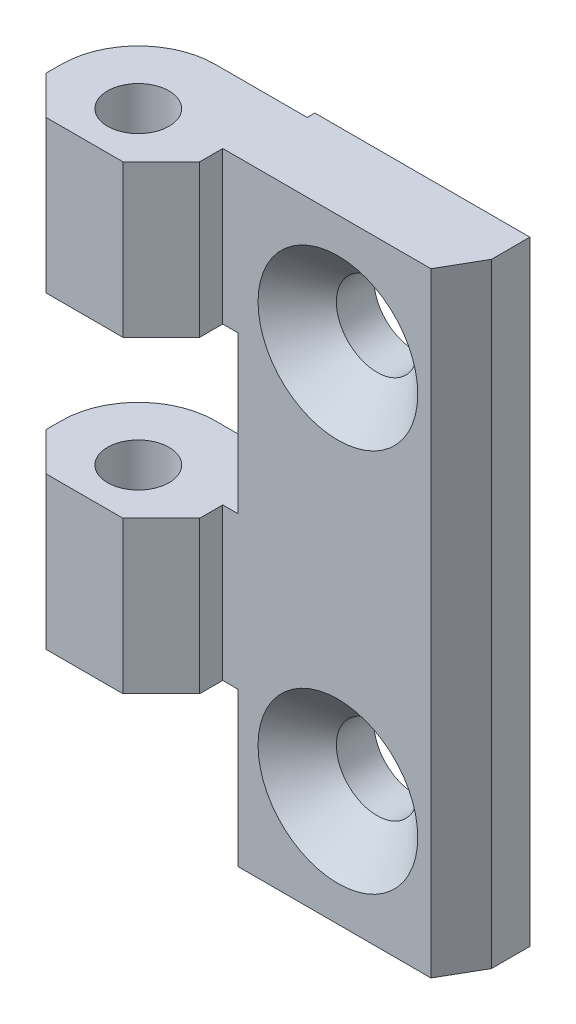
from build123d import *

# Parameters (mm, degrees)
BOSS_EXTRUDE1_DEPTH                            = 40
CUT_EXTRUDE1_DEPTH                             = 40
CSK_FOR_M5_FLAT_HEAD_MACHINE_SCREW1_AT_2_COUNT = 2
CSK_FOR_M5_FLAT_HEAD_MACHINE_SCREW1_AT_2_PITCH = 25
SKETCH7_R                                      = 2
CUT_EXTRUDE2_DEPTH                             = 40
SKETCH8_W                                      = 1
SKETCH8_H                                      = 10.2
CUT_EXTRUDE3_DEPTH                             = 10
SKETCH9_W                                      = 11.70124712
SKETCH9_H                                      = 10.2
CUT_EXTRUDE4_DEPTH                             = 10
CUT_EXTRUDE4_DEPTH_BACK                        = 10
SKETCH10_W                                     = 1
SKETCH10_H                                     = 10
CUT_EXTRUDE5_DEPTH                             = 10
SKETCH11_W                                     = 12.165826364
SKETCH11_H                                     = 10.874220792
CUT_EXTRUDE6_DEPTH                             = 10
CUT_EXTRUDE6_DEPTH_BACK                        = 10


with BuildPart() as part:
    # Sketch2 → Boss-Extrude1 (new body)
    with BuildSketch(Plane(origin=(0, 0, 0), x_dir=(1, 0, 0), z_dir=(0, 1, 0))):
        with BuildLine():
            Line((-2.5, 0), (2.5, 0))
            Line((2.5, 0), (5, 2.5))
            Line((5, 2.5), (5, 4))
            Line((5, 4), (20, 4))
            Line((20, 4), (20, 9))
            Line((20, 9), (6, 9))
            Line((6, 9), (6, 8.5))
            Line((6, 8.5), (0, 8.5))
            ThreePointArc((0, 8.5), (-3.535533906, 7.035533906), (-5, 3.5))
            Line((-5, 3.5), (-5, 2.5))
            Line((-5, 2.5), (-2.5, 0))
        make_face()
    extrude(amount=BOSS_EXTRUDE1_DEPTH)

    # Sketch3 → Cut-Extrude1 (cut)
    with BuildSketch(Plane(origin=(0, 40, 0), x_dir=(1, 0, 0), z_dir=(0, 1, 0))):
        Polygon((20, 6.5), (18.56, 4), (20, 4), align=None)
    extrude(amount=-CUT_EXTRUDE1_DEPTH, mode=Mode.SUBTRACT)

    # Sketch6 → CSK for M5 Flat Head Machine Screw1 (revolve, cut)
    with BuildSketch(Plane(origin=(12.5, 32.5, -4), x_dir=(0, -1, 0), z_dir=(1, 0, 0))):
        Polygon((0, 0), (0, 5), (2.65, 5), (2.65, 2.55), (5.2, 0), align=None)
    csk_for_m5_flat_head_machine_screw1 = revolve(axis=Axis((12.5, 32.5, 2.35), (0, 0, -1)), mode=Mode.SUBTRACT)

    # CSK for M5 Flat Head Machine Screw1 at 2: CSK for M5 Flat Head Machine Screw1 ×2
    with Locations(*[(0, -i * CSK_FOR_M5_FLAT_HEAD_MACHINE_SCREW1_AT_2_PITCH, 0) for i in range(1, CSK_FOR_M5_FLAT_HEAD_MACHINE_SCREW1_AT_2_COUNT)]):
        add(csk_for_m5_flat_head_machine_screw1, mode=Mode.SUBTRACT)

    # Sketch7 → Cut-Extrude2 (cut)
    with BuildSketch(Plane(origin=(0, 40, 0), x_dir=(1, 0, 0), z_dir=(0, 1, 0))):
        with Locations((0, 3.5)):
            Circle(SKETCH7_R)
    extrude(amount=-CUT_EXTRUDE2_DEPTH, mode=Mode.SUBTRACT)

    # Sketch8 → Cut-Extrude3 (cut)
    with BuildSketch(Plane.XY.offset(-4)):
        with Locations((5.5, 25)):
            Rectangle(SKETCH8_W, SKETCH8_H)
    extrude(amount=-CUT_EXTRUDE3_DEPTH, mode=Mode.SUBTRACT)

    # Sketch9 → Cut-Extrude4 (cut, two sides)
    with BuildSketch(Plane.XY.offset(-4)) as cut_extrude4_sk:
        with Locations((0.14937644, 25)):
            Rectangle(SKETCH9_W, SKETCH9_H)
    extrude(amount=CUT_EXTRUDE4_DEPTH, mode=Mode.SUBTRACT)
    extrude(cut_extrude4_sk.sketch, amount=-CUT_EXTRUDE4_DEPTH_BACK, mode=Mode.SUBTRACT)

    # Sketch10 → Cut-Extrude5 (cut)
    with BuildSketch(Plane.XY.offset(-4)):
        with Locations((5.5, 5)):
            Rectangle(SKETCH10_W, SKETCH10_H)
    extrude(amount=-CUT_EXTRUDE5_DEPTH, mode=Mode.SUBTRACT)

    # Sketch11 → Cut-Extrude6 (cut, two sides)
    with BuildSketch(Plane.XY.offset(-4)) as cut_extrude6_sk:
        with Locations((-0.082913182, 4.562889604)):
            Rectangle(SKETCH11_W, SKETCH11_H)
    extrude(amount=CUT_EXTRUDE6_DEPTH, mode=Mode.SUBTRACT)
    extrude(cut_extrude6_sk.sketch, amount=-CUT_EXTRUDE6_DEPTH_BACK, mode=Mode.SUBTRACT)


solid = part.part
